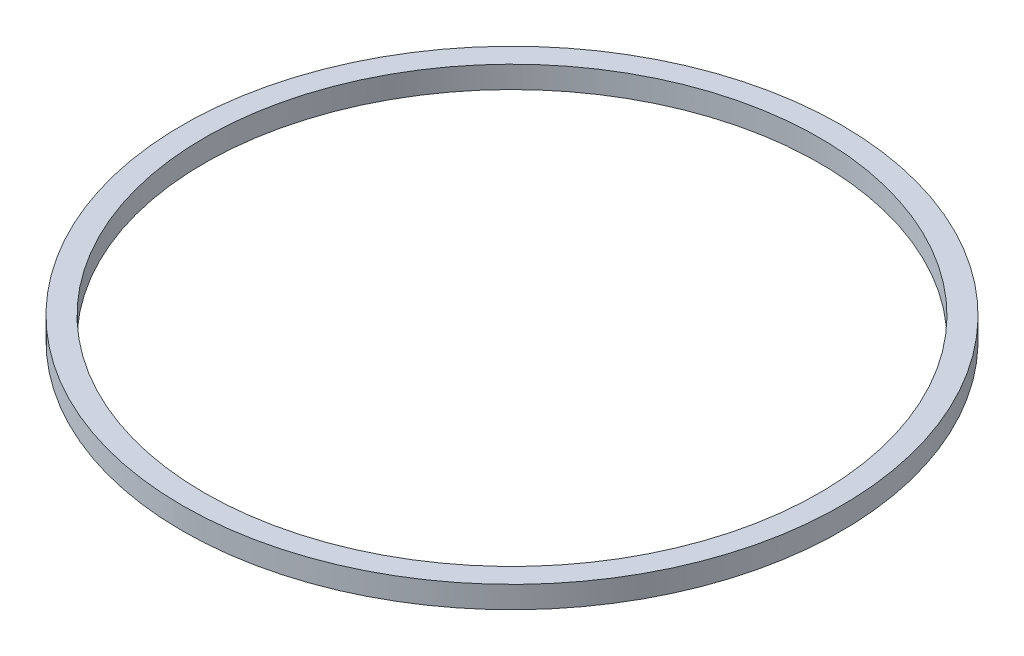
from build123d import *

# Parameters (mm, degrees)
SKETCH3_R           = 38.1
SKETCH3_R_2         = 35.56
BOSS_EXTRUDE5_DEPTH = 2.54


with BuildPart() as part:
    # Sketch3 → Boss-Extrude5 (new body)
    with BuildSketch(Plane(origin=(0, 0, 0), x_dir=(1, 0, 0), z_dir=(0, 1, 0))):
        with Locations(Location((64.004487688, 73.693240411, 0), (0, 0, 270))):  # turned: the seam where the file's is
            Circle(SKETCH3_R)
        with Locations(Location((64.004487688, 73.693240411, 0), (0, 0, 270))):  # turned: the seam where the file's is
            Circle(SKETCH3_R_2, mode=Mode.SUBTRACT)
    extrude(amount=BOSS_EXTRUDE5_DEPTH)


solid = part.part
